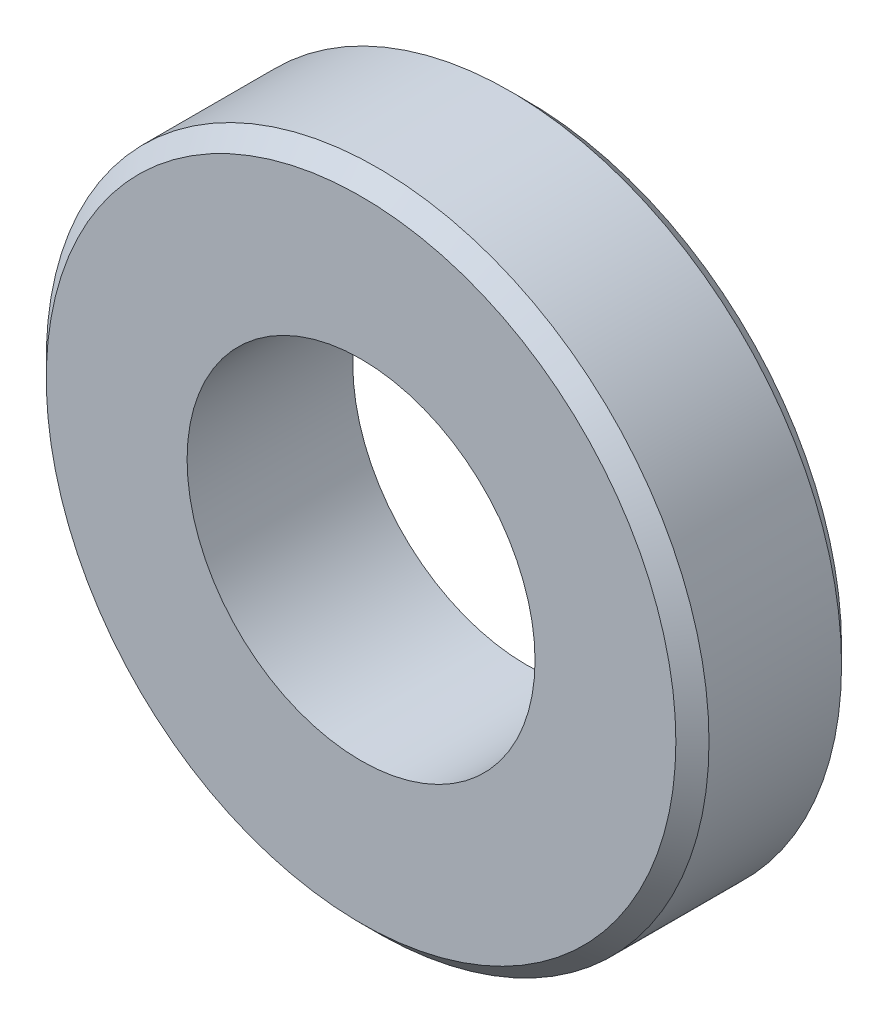
from build123d import *

# Parameters (mm, degrees)
SKETCH_1_R      = 4
SKETCH_1_R_2    = 2.1
EXTRUDE_1_DEPTH = 1
CHAMFER_1_SIZE  = 0.2


with BuildPart() as part:
    # 草图1 → 凸台-拉伸1 (new body, symmetric)
    with BuildSketch(Plane.XY):
        Circle(SKETCH_1_R)
        Circle(SKETCH_1_R_2, mode=Mode.SUBTRACT)
    extrude(amount=EXTRUDE_1_DEPTH, both=True)

    # 倒角1
    chamfer_1_edges = [part.edges().sort_by_distance(p)[0] for p in [
        (-4, 0, -1),
        (-4, 0, 1),
    ]]
    chamfer(chamfer_1_edges, length=CHAMFER_1_SIZE)


solid = part.part
